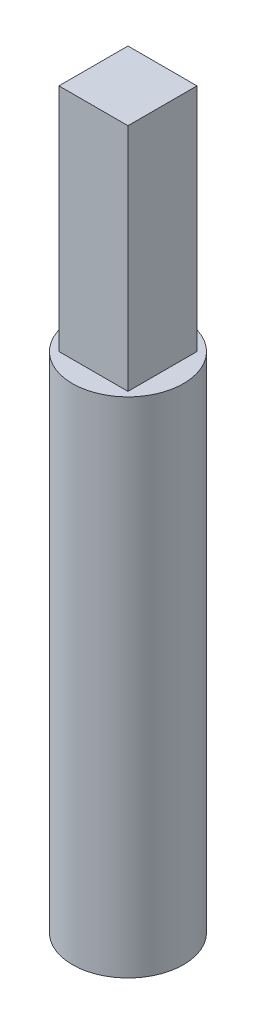
from build123d import *

# Parameters (mm, degrees)
SKETCH1_R           = 3.68046
BOSS_EXTRUDE1_DEPTH = 33.3375
SKETCH3_W           = 4.572
SKETCH3_H           = 4.572
BOSS_EXTRUDE2_DEPTH = 15.24


with BuildPart() as part:
    # Sketch1 → Boss-Extrude1 (new body)
    with BuildSketch(Plane(origin=(0, 0, 0), x_dir=(1, 0, 0), z_dir=(0, 1, 0))):
        Circle(SKETCH1_R)
    extrude(amount=BOSS_EXTRUDE1_DEPTH)

    # Sketch3 → Boss-Extrude2 (add)
    with BuildSketch(Plane(origin=(0, 33.3375, 0), x_dir=(1, 0, 0), z_dir=(0, 1, 0))):
        Rectangle(SKETCH3_W, SKETCH3_H)
    extrude(amount=BOSS_EXTRUDE2_DEPTH)


solid = part.part
